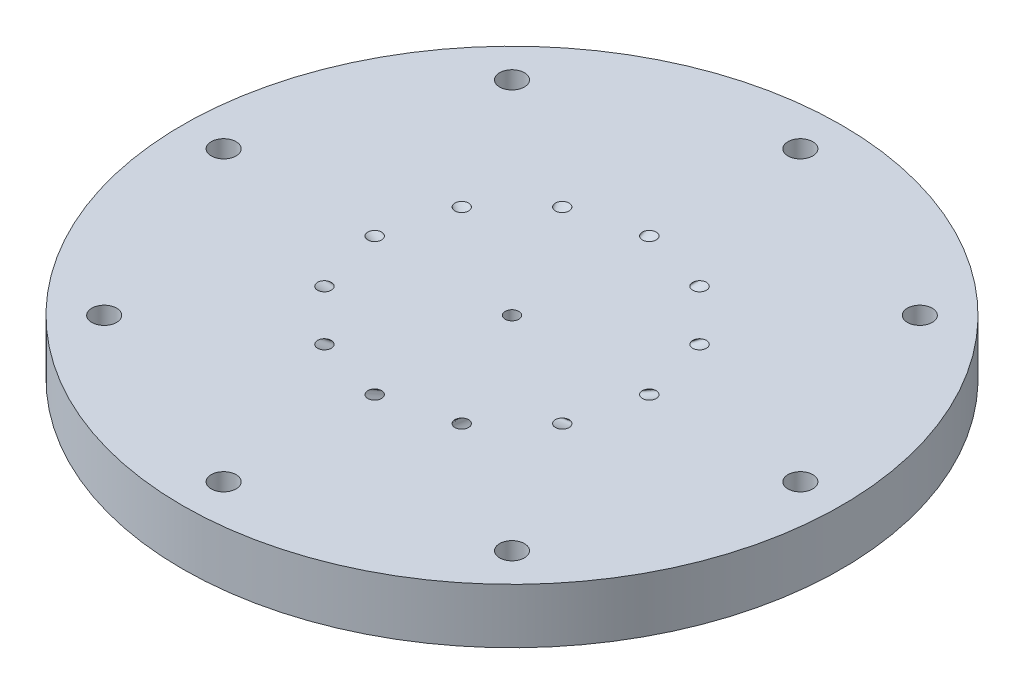
from build123d import *

# Parameters (mm, degrees)
SKETCH1_R                                      = 38.1
BOSS_EXTRUDE1_DEPTH                            = 6.35
CBORE_FOR_4_BUTTON_HEAD_CAP_SCREW1_D           = 2.8702
CBORE_FOR_4_BUTTON_HEAD_CAP_SCREW1_CBORE_D     = 4.826
CBORE_FOR_4_BUTTON_HEAD_CAP_SCREW1_CBORE_DEPTH = 1.905
CIRPATTERN1_COUNT                              = 8
SKETCH6_R                                      = 0.79375
CUT_EXTRUDE1_DEPTH                             = 55.254423783
CUT_EXTRUDE1_DEPTH_BACK                        = 55.254423783
SKETCH7_R                                      = 0.79375
CIRPATTERN2_COUNT                              = 12


with BuildPart() as part:
    # Sketch1 → Boss-Extrude1 (new body)
    with BuildSketch(Plane(origin=(0, 0, 0), x_dir=(1, 0, 0), z_dir=(0, 1, 0))):
        with Locations(Location((0, 0, 0), (0, 0, 270))):
            Circle(SKETCH1_R)
    extrude(amount=BOSS_EXTRUDE1_DEPTH)

    # CBORE for #4 Button Head Cap Screw1 (through all)
    with Locations(Plane(origin=(0, 0, 0), x_dir=(-1, 0, 0), z_dir=(0, -1, 0))):
        with Locations((0, -33.3375)):
            cbore_for_4_button_head_cap_screw1 = CounterBoreHole(CBORE_FOR_4_BUTTON_HEAD_CAP_SCREW1_D / 2, CBORE_FOR_4_BUTTON_HEAD_CAP_SCREW1_CBORE_D / 2, CBORE_FOR_4_BUTTON_HEAD_CAP_SCREW1_CBORE_DEPTH)

    # CirPattern1: CBORE for #4 Button Head Cap Screw1 ×8 about axis
    cirpattern1_axis = Axis((0, 0, 0), (0, 1, 0))
    for i in range(1, CIRPATTERN1_COUNT):
        add(cbore_for_4_button_head_cap_screw1.rotate(cirpattern1_axis, i * 360 / CIRPATTERN1_COUNT), mode=Mode.SUBTRACT)

    # Sketch6 → Cut-Extrude1 (cut, two sides)
    with BuildSketch(Plane(origin=(0, 6.35, 0), x_dir=(1, 0, 0), z_dir=(0, 1, 0))) as cut_extrude1_sk:
        with Locations(Location((0, 0, 0), (0, 0, 270))):
            Circle(SKETCH6_R)
    extrude(amount=CUT_EXTRUDE1_DEPTH, mode=Mode.SUBTRACT)
    extrude(cut_extrude1_sk.sketch, amount=-CUT_EXTRUDE1_DEPTH_BACK, mode=Mode.SUBTRACT)

    # Cut-Sweep1: sweep along a curve in space
    with BuildLine() as cut_sweep1_path:
        Line((0, 6.35, -15.875), (0, 0, -4.445))
    # Sketch7 → Cut-Sweep1 (sweep, cut)
    with BuildSketch(Plane(origin=(0, 6.35, 0), x_dir=(1, 0, 0), z_dir=(0, 1, 0))):
        with Locations((0, 15.875)):
            Circle(SKETCH7_R)
    cut_sweep1 = sweep(path=cut_sweep1_path.line, mode=Mode.SUBTRACT)

    # CirPattern2: Cut-Sweep1 ×12 about axis
    cirpattern2_axis = Axis((0, 6.35, 0), (0, 1, 0))
    for i in range(1, CIRPATTERN2_COUNT):
        add(cut_sweep1.rotate(cirpattern2_axis, i * 360 / CIRPATTERN2_COUNT), mode=Mode.SUBTRACT)


solid = part.part
